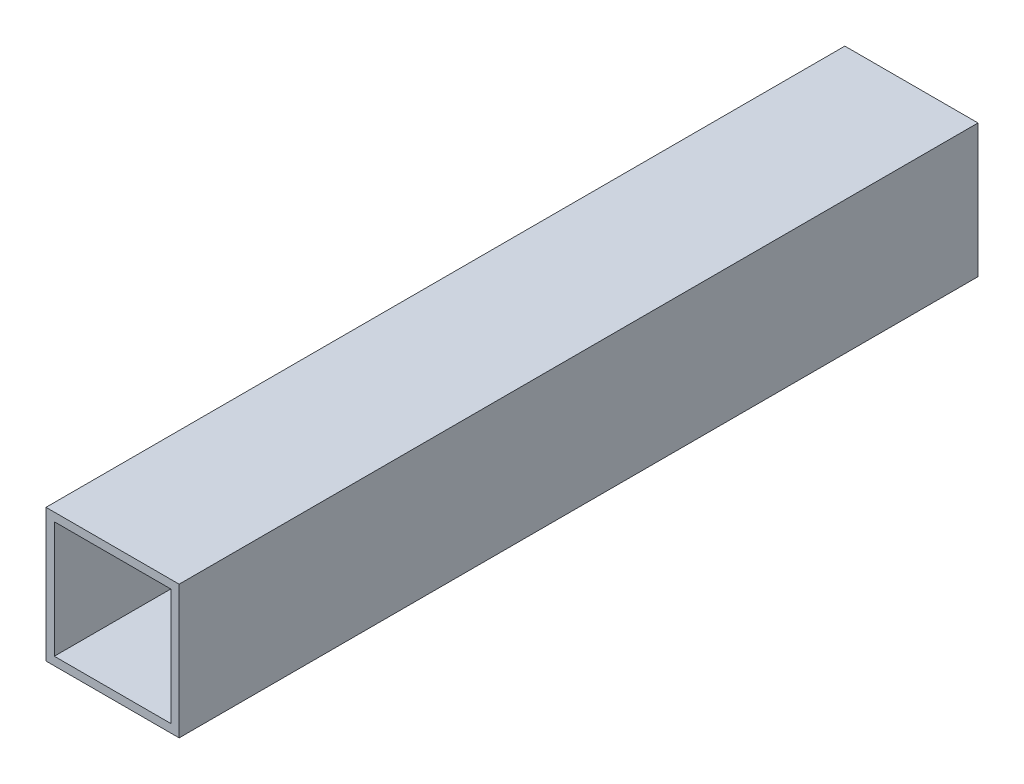
from build123d import *

# Parameters (mm, degrees)
SKETCH3_W                = 25.4
SKETCH3_H                = 25.4
SKETCH3_W_2              = 22.225
SKETCH3_H_2              = 22.225
BOSS_EXTRUDE1_DEPTH      = 76.2
BOSS_EXTRUDE1_DEPTH_BACK = 76.2


with BuildPart() as part:
    # Sketch3 → Boss-Extrude1 (new body, two sides)
    with BuildSketch(Plane.XY) as boss_extrude1_sk:
        Rectangle(SKETCH3_W, SKETCH3_H)
        Rectangle(SKETCH3_W_2, SKETCH3_H_2, mode=Mode.SUBTRACT)
    extrude(amount=BOSS_EXTRUDE1_DEPTH)
    extrude(boss_extrude1_sk.sketch, amount=-BOSS_EXTRUDE1_DEPTH_BACK)


solid = part.part
